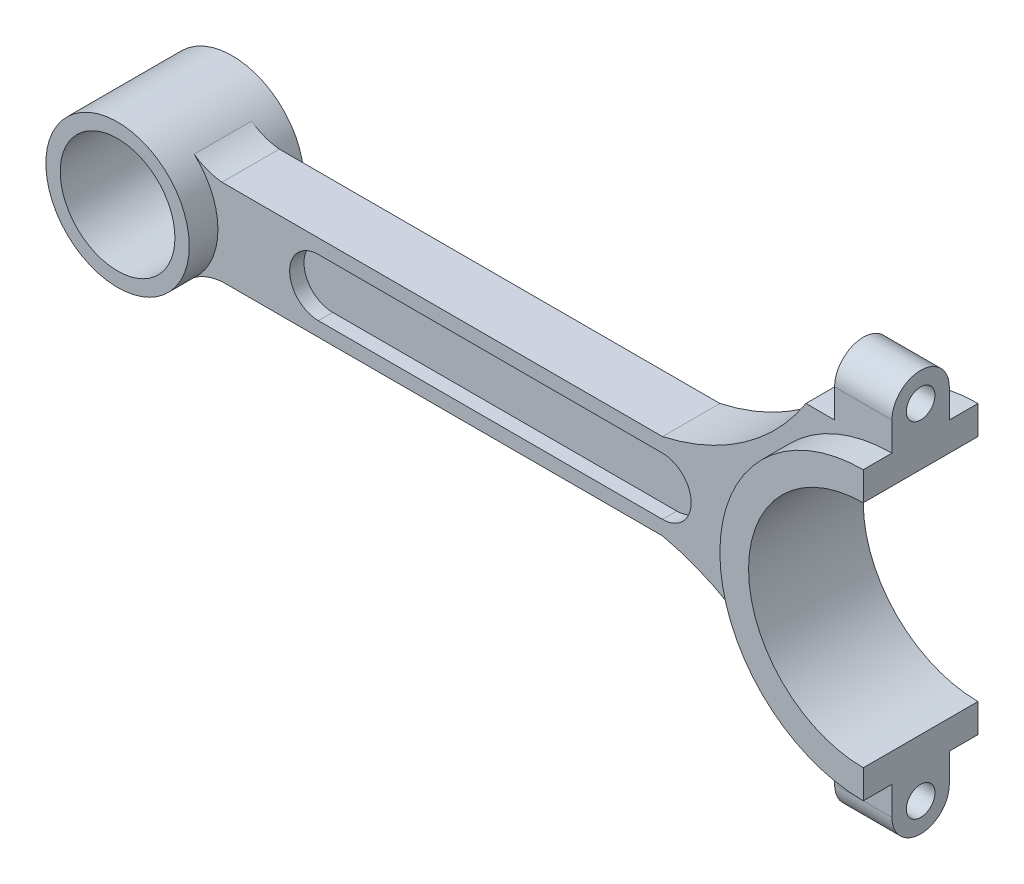
from build123d import *

# Parameters (mm, degrees)
SKETCH2_R             = 31.75
BOSS_EXTRUDE2_DEPTH   = 12.7
SKETCH2_R_2           = 15.875
BOSS_EXTRUDE2_2_DEPTH = 12.7
BOSS_EXTRUDE3_START   = -6.35
BOSS_EXTRUDE3_DEPTH   = 12.7
CUT_EXTRUDE1_DEPTH    = 3.175
SKETCH5_R             = 12.7
CUT_EXTRUDE2_DEPTH    = 26.4
BOSS_EXTRUDE4_DEPTH   = 12.7
SKETCH7_R             = 3.175
CUT_EXTRUDE3_DEPTH    = 12.7


with BuildPart() as part:
    # Sketch2 → Boss-Extrude2 (new body, symmetric)
    with BuildSketch(Plane.XY):
        Circle(SKETCH2_R)
    extrude(amount=BOSS_EXTRUDE2_DEPTH, both=True)


with BuildPart() as body_2:
    # Sketch2 → Boss-Extrude2 2 (new body, symmetric)
    with BuildSketch(Plane.XY):
        with Locations((-165.1, 0)):
            Circle(SKETCH2_R_2)
    extrude(amount=BOSS_EXTRUDE2_2_DEPTH, both=True)


with BuildPart() as body_3:
    # Sketch3 → Boss-Extrude3 (new body)
    with BuildSketch(Plane.XY.offset(12.7).offset(BOSS_EXTRUDE3_START)):
        with BuildLine():
            Line((0, 31.75), (-19.05, 31.75))
            ThreePointArc((-19.05, 31.75), (-32.7222642, 17.490734571), (-50.8, 9.525))
            Line((-50.8, 9.525), (-148.343009524, 9.525))
            ThreePointArc((-148.343009524, 9.525), (-151.567861624, 10.263966545), (-154.492422733, 11.810797159))
            Line((-154.492422733, 11.810797159), (-154.492422733, -11.810797159))
            ThreePointArc((-154.492422733, -11.810797159), (-151.567861624, -10.263966545), (-148.343009524, -9.525))
            Line((-148.343009524, -9.525), (-50.8, -9.525))
            ThreePointArc((-50.8, -9.525), (-32.7222642, -17.490734571), (-19.05, -31.75))
            Line((-19.05, -31.75), (0, -31.75))
            Line((0, -31.75), (0, 31.75))
        make_face()
    extrude(amount=-BOSS_EXTRUDE3_DEPTH)

    # Sketch4 → Cut-Extrude1 (cut)
    with BuildSketch(Plane.XY.offset(6.35)):
        with BuildLine():
            Line((-127, 6.35), (-50.8, 6.35))
            ThreePointArc((-50.8, 6.35), (-44.45, 0), (-50.8, -6.35))
            Line((-50.8, -6.35), (-127, -6.35))
            ThreePointArc((-127, -6.35), (-133.35, 0), (-127, 6.35))
        make_face()
    cut_extrude1 = extrude(amount=-CUT_EXTRUDE1_DEPTH, mode=Mode.SUBTRACT)

    # Mirror1: Cut-Extrude1 across plane
    add(cut_extrude1.mirror(Plane.XY), mode=Mode.SUBTRACT)


with BuildPart() as cut_extrude2_tool:
    # Sketch5 → Cut-Extrude2 (new body, through all)
    with BuildSketch(Plane.XY.offset(12.7)):
        with Locations((-165.1, 0)):
            Circle(SKETCH5_R)
        with BuildLine():
            Line((0, 31.75), (33.396136352, 31.75))
            Line((33.396136352, 31.75), (33.396136352, -31.75))
            Line((33.396136352, -31.75), (0, -31.75))
            Line((0, -31.75), (0, -25.4))
            ThreePointArc((0, -25.4), (-25.4, 0), (0, 25.4))
            Line((0, 25.4), (0, 31.75))
        make_face()
    extrude(amount=-CUT_EXTRUDE2_DEPTH)


with BuildPart() as part_1:
    add(part.part)

    # Cut-Extrude2: cut by cut_extrude2_tool
    add(cut_extrude2_tool.part, mode=Mode.SUBTRACT)



with BuildPart() as body_2_1:
    add(body_2.part)

    # Cut-Extrude2: cut by cut_extrude2_tool
    add(cut_extrude2_tool.part, mode=Mode.SUBTRACT)


with BuildPart() as body_3_1:
    add(body_3.part)

    # Cut-Extrude2: cut by cut_extrude2_tool
    add(cut_extrude2_tool.part, mode=Mode.SUBTRACT)


with BuildPart() as part_2:
    add(part_1.part)

    add(body_3_1.part)  # Boss-Extrude4 merges body 3
    # Sketch6 → Boss-Extrude4 (add)
    with BuildSketch(Plane(origin=(0, 0, 0), x_dir=(0, 0, -1), z_dir=(1, 0, 0))):
        with BuildLine():
            Line((-6.35, 25.4), (6.35, 25.4))
            Line((6.35, 25.4), (6.35, 38.1))
            ThreePointArc((6.35, 38.1), (0, 44.45), (-6.35, 38.1))
            Line((-6.35, 38.1), (-6.35, 25.4))
        make_face()
    boss_extrude4 = extrude(amount=-BOSS_EXTRUDE4_DEPTH)

    # Mirror2: Boss-Extrude4 across plane
    add(boss_extrude4.mirror(Plane.ZX))

    # Sketch7 → Cut-Extrude3 (cut)
    with BuildSketch(Plane(origin=(0, 0, 0), x_dir=(0, 0, -1), z_dir=(1, 0, 0))):
        with Locations((0, 38.1)):
            Circle(SKETCH7_R)
    cut_extrude3 = extrude(amount=-CUT_EXTRUDE3_DEPTH, mode=Mode.SUBTRACT)

    # Mirror3: Cut-Extrude3 across plane
    add(cut_extrude3.mirror(Plane.ZX), mode=Mode.SUBTRACT)


solid = Compound([body_2_1.part, part_2.part])
